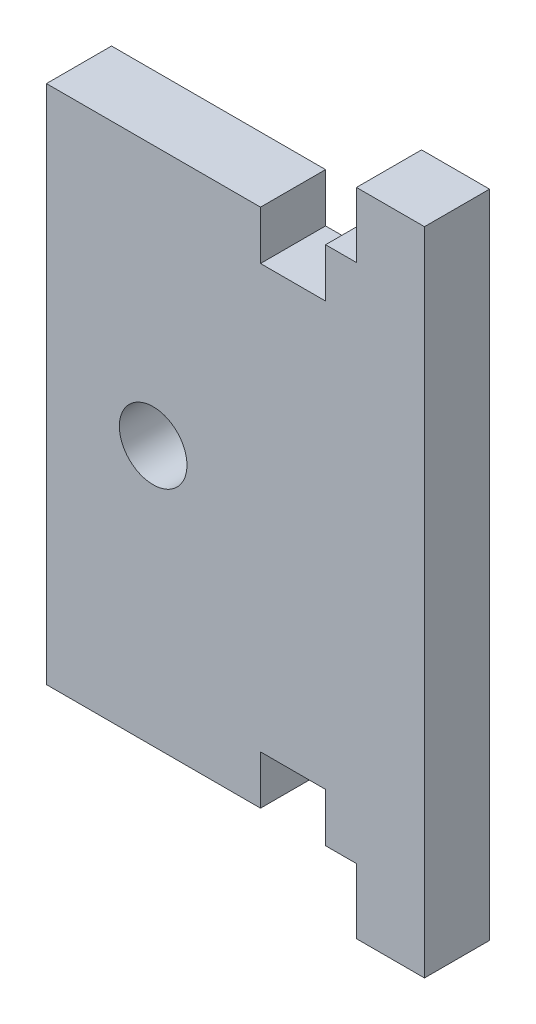
from build123d import *

# Parameters (mm, degrees)
SKETCH2_W               = 43.942
SKETCH2_H               = 127
BOSS_EXTRUDE1_DEPTH     = 6.35
M6_CLEARANCE_HOLE1_D    = 6.6
SKETCH5_W               = 7.0505
SKETCH5_H               = 127
CUT_EXTRUDE1_DEPTH      = 1
CUT_EXTRUDE1_DEPTH_BACK = 7.35
SKETCH6_W               = 27.8745
SKETCH6_H               = 3.175
CUT_EXTRUDE2_DEPTH      = 7.35
SKETCH7_W               = 6.35
SKETCH7_H               = 4.7625
CUT_EXTRUDE3_DEPTH      = 7.35
SKETCH8_R               = 3.3
CUT_EXTRUDE4_DEPTH      = 1
CUT_EXTRUDE4_DEPTH_BACK = 7.35


with BuildPart() as part:
    # Sketch2 → Boss-Extrude1 (new body)
    with BuildSketch(Plane.XY):
        with Locations((21.971, 63.5)):
            Rectangle(SKETCH2_W, SKETCH2_H)
    extrude(amount=BOSS_EXTRUDE1_DEPTH)

    # M6 Clearance Hole1 (through all)
    with Locations(Plane.XY.offset(6.35)):
        with Locations((17.4625, 31.75), (17.4625, 95.25)):
            Hole(M6_CLEARANCE_HOLE1_D / 2)

    # Sketch5 → Cut-Extrude1 (cut, two sides)
    with BuildSketch(Plane.XY.offset(6.35)) as cut_extrude1_sk:
        with Locations((3.52525, 63.5)):
            Rectangle(SKETCH5_W, SKETCH5_H)
    extrude(amount=CUT_EXTRUDE1_DEPTH, mode=Mode.SUBTRACT)
    extrude(cut_extrude1_sk.sketch, amount=-CUT_EXTRUDE1_DEPTH_BACK, mode=Mode.SUBTRACT)

    # Sketch6 → Cut-Extrude2 (cut, through all)
    with BuildSketch(Plane.XY.offset(6.35)):
        Polygon((7.0505, 123.825), (7.0505, 120.65), (37.30625, 120.65), (37.30625, 127), (34.925, 127), (34.925, 123.825), align=None)
        with Locations((20.98775, 125.4125)):
            Rectangle(SKETCH6_W, SKETCH6_H)
        Polygon((37.30625, 66.675), (7.0505, 66.675), (7.0505, 63.5), (34.925, 63.5), (34.925, 60.325), (7.0505, 60.325), (7.0505, 57.15), (37.30625, 57.15), align=None)
        with Locations((20.98775, 61.9125)):
            Rectangle(SKETCH6_W, SKETCH6_H)
        Polygon((37.30625, 0), (37.30625, 6.35), (7.0505, 6.35), (7.0505, 3.175), (34.925, 3.175), (34.925, 0), align=None)
        with Locations((20.98775, 1.5875)):
            Rectangle(SKETCH6_W, SKETCH6_H)
    extrude(amount=-CUT_EXTRUDE2_DEPTH, mode=Mode.SUBTRACT)

    # Sketch7 → Cut-Extrude3 (cut, through all)
    with BuildSketch(Plane.XY.offset(6.35)):
        with Locations((31.115, 118.26875)):
            Rectangle(SKETCH7_W, SKETCH7_H)
        with Locations((31.115, 69.05625)):
            Rectangle(SKETCH7_W, SKETCH7_H)
        with Locations((31.115, 54.76875)):
            Rectangle(SKETCH7_W, SKETCH7_H)
        with Locations((31.115, 8.73125)):
            Rectangle(SKETCH7_W, SKETCH7_H)
    extrude(amount=-CUT_EXTRUDE3_DEPTH, mode=Mode.SUBTRACT)

    # Sketch8 → Cut-Extrude4 (cut, two sides)
    with BuildSketch(Plane.XY.offset(6.35)) as cut_extrude4_sk:
        Polygon((37.30625, 66.675), (37.30625, 63.5), (43.942, 63.5), (43.942, 127), (37.30625, 127), (37.30625, 120.65), (34.29, 120.65), (34.29, 115.8875), (27.94, 115.8875), (27.94, 120.65), (7.0505, 120.65), (7.0505, 66.675), (27.94, 66.675), (27.94, 71.4375), (34.29, 71.4375), (34.29, 66.675), align=None)
        with Locations((17.4625, 95.25)):
            Circle(SKETCH8_R, mode=Mode.SUBTRACT)
    extrude(amount=CUT_EXTRUDE4_DEPTH, mode=Mode.SUBTRACT)
    extrude(cut_extrude4_sk.sketch, amount=-CUT_EXTRUDE4_DEPTH_BACK, mode=Mode.SUBTRACT)


solid = part.part
